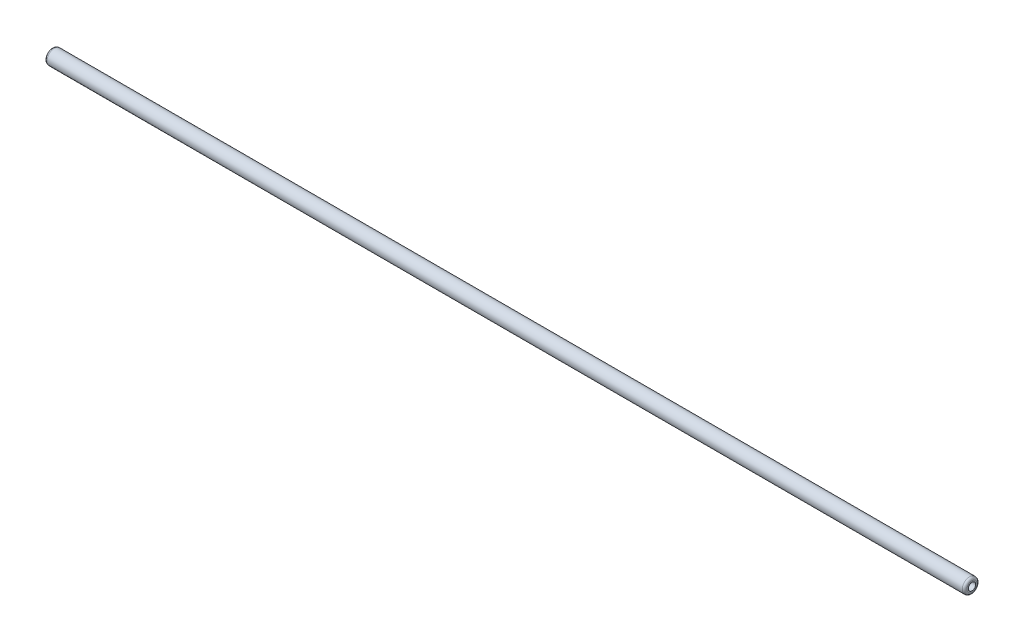
from build123d import *

# Parameters (mm, degrees)
SKETCH_1_R        = 7.9375
SKETCH_1_R_2      = 3.975
EXTRUDE_1_DEPTH   = 493.649
FILLET_1_R        = 2.5
MOVE_BODY_1_ANGLE = 90


with BuildPart() as part:
    # 스케치1 → 보스-돌출1 (new body, symmetric)
    with BuildSketch(Plane(origin=(0, 0, 0), x_dir=(1, 0, 0), z_dir=(0, 1, 0))):
        Circle(SKETCH_1_R)
        Circle(SKETCH_1_R_2, mode=Mode.SUBTRACT)
    extrude(amount=EXTRUDE_1_DEPTH, both=True)

    # 필렛1
    fillet_1_edges = [part.edges().sort_by_distance(p)[0] for p in [
        (-7.9375, -493.649, 0),
        (-7.9375, 493.649, 0),
    ]]
    fillet(fillet_1_edges, radius=FILLET_1_R)


with BuildPart() as part_1:
    # Move Body 1: moved
    add(part.part.rotate(Axis((0, 0, 0), (0, 0, 1)), MOVE_BODY_1_ANGLE))


solid = part_1.part
